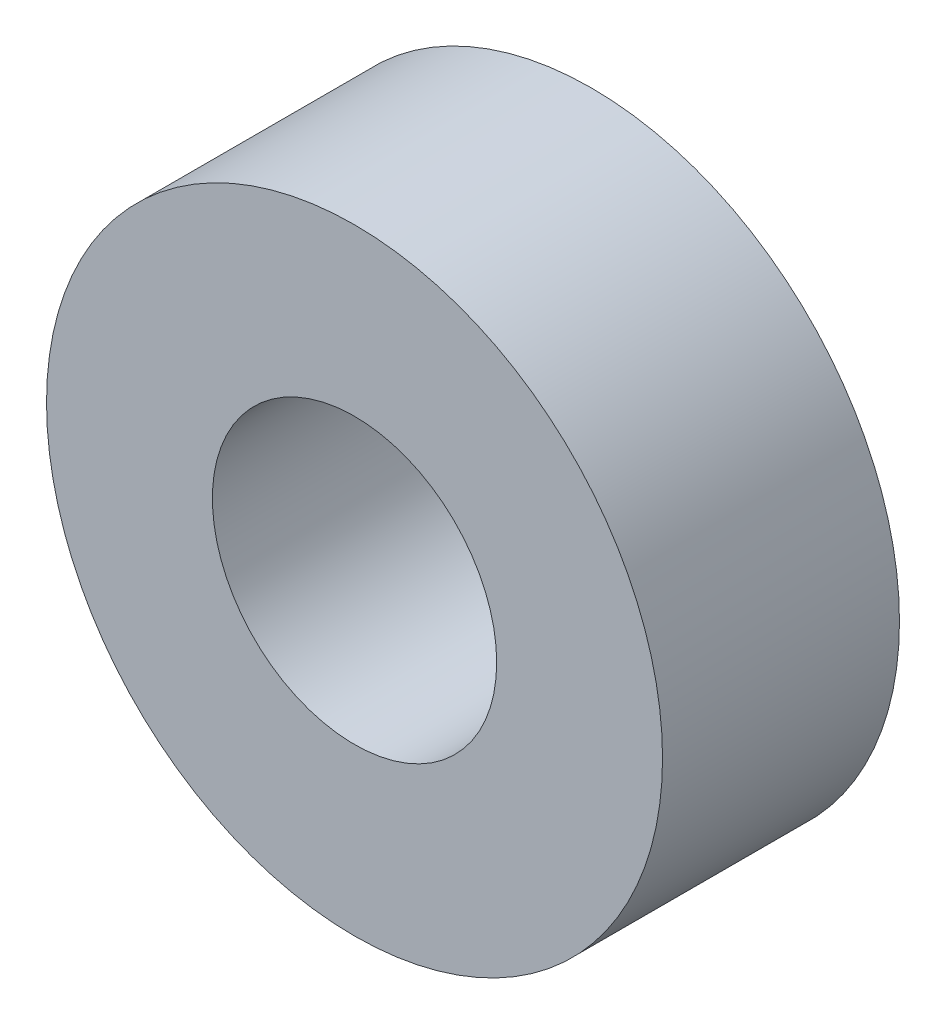
from build123d import *

# Parameters (mm, degrees)
SKETCH1_R           = 20.6375
SKETCH1_R_2         = 9.525
BOSS_EXTRUDE1_DEPTH = 15.875


with BuildPart() as part:
    # Sketch1 → Boss-Extrude1 (new body)
    with BuildSketch(Plane.XY):
        Circle(SKETCH1_R)
        Circle(SKETCH1_R_2, mode=Mode.SUBTRACT)
    extrude(amount=BOSS_EXTRUDE1_DEPTH)


solid = part.part
